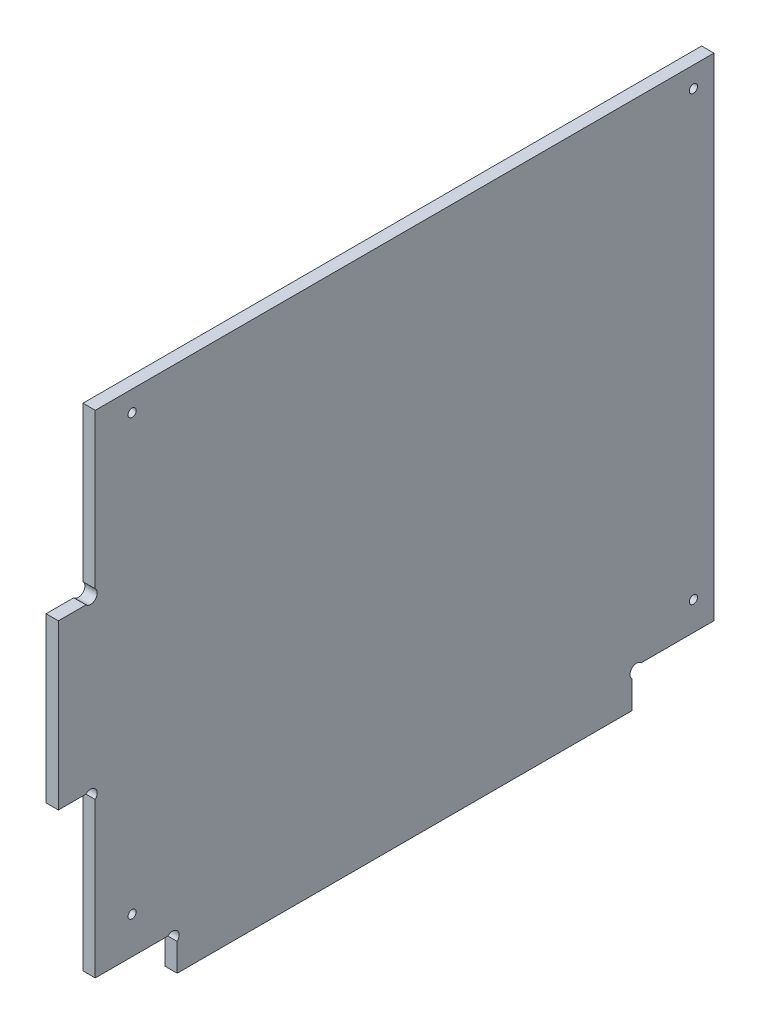
from build123d import *

# Parameters (mm, degrees)
EXTRUSION1_DEPTH        = 3
ESQUISSE2_R             = 1
ENL_V_MAT_EXTRU_1_DEPTH = 4


with BuildPart() as part:
    # Esquisse1 → Extrusion1 (new body)
    with BuildSketch(Plane(origin=(0, 0, 0), x_dir=(0, 0, -1), z_dir=(1, 0, 0))):
        with BuildLine():
            Line((140, 6.7372583), (140, 0))
            Line((140, 0), (29, 0))
            Line((29, 0), (29, 6.7372583))
            ThreePointArc((29, 6.7372583), (29, 9), (26.7372583, 9))
            Line((26.7372583, 9), (9, 9))
            Line((9, 9), (9, 46.7372583))
            ThreePointArc((9, 46.7372583), (9, 49), (6.7372583, 49))
            Line((6.7372583, 49), (0, 49))
            Line((0, 49), (0, 89))
            Line((0, 89), (6.7372583, 89))
            ThreePointArc((6.7372583, 89), (9, 89), (9, 91.2627417))
            Line((9, 91.2627417), (9, 129))
            Line((9, 129), (160, 129))
            Line((160, 129), (160, 9))
            Line((160, 9), (142.2627417, 9))
            ThreePointArc((142.2627417, 9), (140, 9), (140, 6.7372583))
        make_face()
    extrude(amount=EXTRUSION1_DEPTH)

    # Esquisse2 → Enlèv. mat.-Extru.1 (cut, through all)
    with BuildSketch(Plane(origin=(3, 0, 0), x_dir=(0, 0, -1), z_dir=(1, 0, 0))):
        with Locations((18, 124)):
            Circle(ESQUISSE2_R)
        with Locations((155, 124)):
            Circle(ESQUISSE2_R)
        with Locations((18, 18)):
            Circle(ESQUISSE2_R)
        with Locations((155, 16)):
            Circle(ESQUISSE2_R)
    extrude(amount=-ENL_V_MAT_EXTRU_1_DEPTH, mode=Mode.SUBTRACT)


solid = part.part
